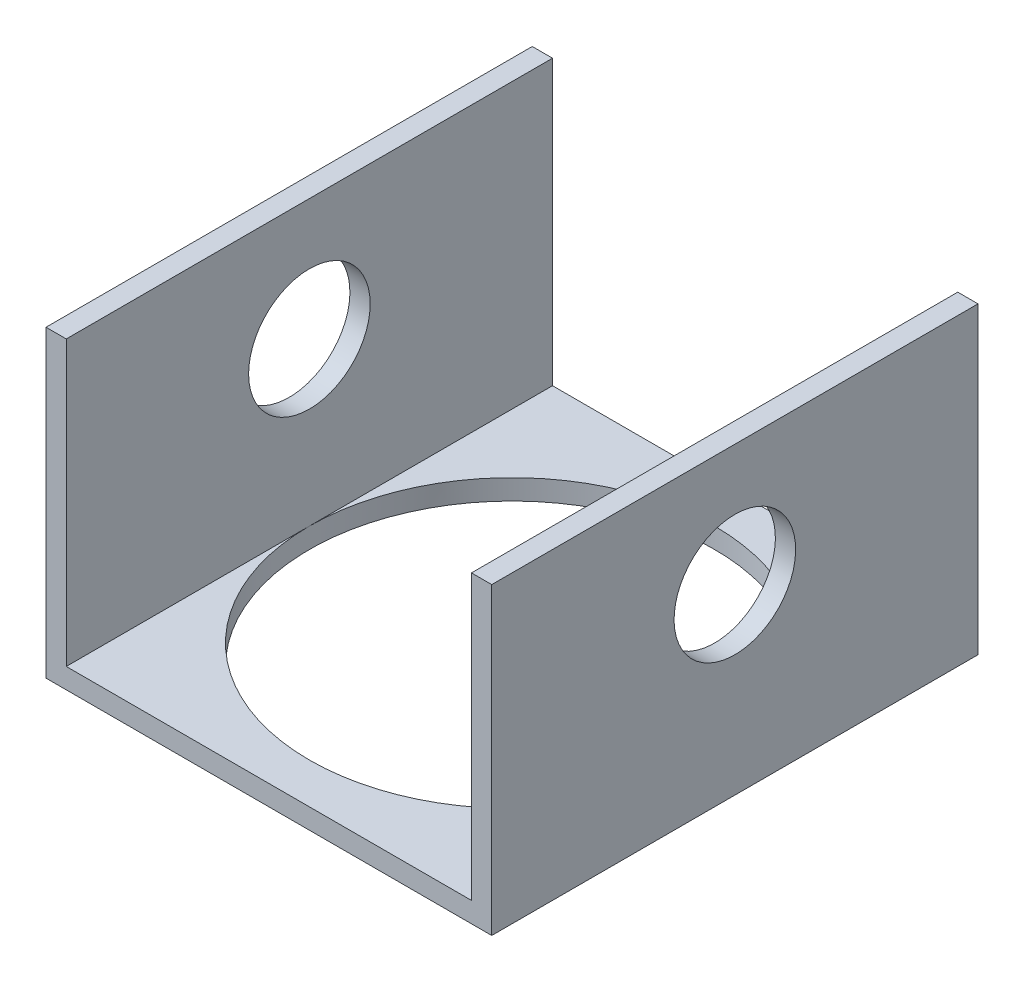
from build123d import *

# Parameters (mm, degrees)
BOSS_EXTRUDE1_DEPTH = 38.1
SKETCH2_R           = 9.525
CUT_EXTRUDE1_DEPTH  = 70.85
SKETCH3_R           = 31.75
CUT_EXTRUDE2_DEPTH  = 48.625


with BuildPart() as part:
    # Sketch1 → Boss-Extrude1 (new body, symmetric)
    with BuildSketch(Plane.XY):
        Polygon((-31.75, 0), (31.75, 0), (31.75, 44.45), (34.925, 44.45), (34.925, -3.175), (-34.925, -3.175), (-34.925, 44.45), (-31.75, 44.45), align=None)
    extrude(amount=BOSS_EXTRUDE1_DEPTH, both=True)

    # Sketch2 → Cut-Extrude1 (cut, through all)
    with BuildSketch(Plane(origin=(34.925, 0, 0), x_dir=(0, 0, -1), z_dir=(1, 0, 0))):
        with Locations((0, 25.4)):
            Circle(SKETCH2_R)
    extrude(amount=-CUT_EXTRUDE1_DEPTH, mode=Mode.SUBTRACT)

    # Sketch3 → Cut-Extrude2 (cut, through all)
    with BuildSketch(Plane.XZ.offset(3.175)):
        Circle(SKETCH3_R)
    extrude(amount=-CUT_EXTRUDE2_DEPTH, mode=Mode.SUBTRACT)


solid = part.part
